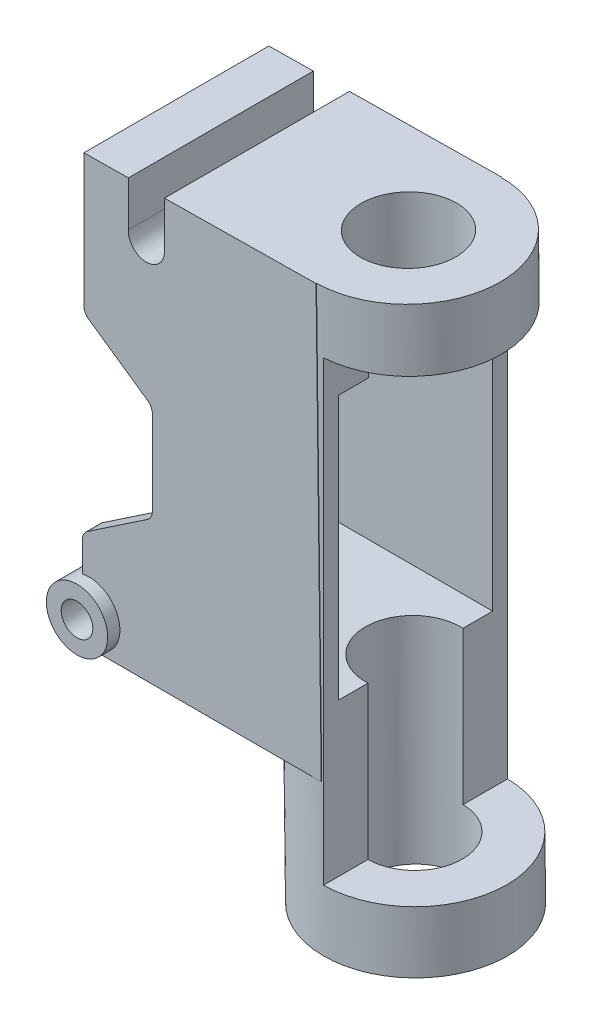
from build123d import *

# Parameters (mm, degrees)
BOSS_EXTRUDE1_DEPTH               = 60.325
BOSS_EXTRUDE2_START               = -64.325
SKETCH4_R                         = 10
BOSS_EXTRUDE2_DEPTH               = 68.325
SKETCH5_R                         = 5.159375
CUT_EXTRUDE1_DEPTH                = 69.325
SKETCH6_W                         = 75.649114878
SKETCH6_H                         = 60.325
BOSS_EXTRUDE3_DEPTH               = 1.8288
BOSS_EXTRUDE4_REACH               = 190.905
BOSS_EXTRUDE4_OFFSET_FROM_SURFACE = 49
SKETCH8_R                         = 30
SKETCH9_R                         = 15.5
CUT_EXTRUDE2_DEPTH                = 190.266787166
CUT_EXTRUDE3_DEPTH                = 49
SKETCH11_W                        = 50.325
SKETCH11_H                        = 86.143116626
CUT_EXTRUDE4_DEPTH                = 109.525496818
SKETCH15_R                        = 3.175
CUT_EXTRUDE5_DEPTH                = 190.266787166
FILLET1_R                         = 3.81


with BuildPart() as part:
    # Sketch2 → Boss-Extrude1 (new body)
    with BuildSketch(Plane.XY):
        with BuildLine():
            Line((12.765629792, 129.146573189), (-1.754589441, 128.968962917))
            Line((-1.754589441, 128.968962917), (-1.754589441, 83.82382539))
            Line((-1.754589441, 83.82382539), (20.592124083, 68.316599476))
            Line((20.592124083, 68.316599476), (20.592124083, 36.846052768))
            Line((20.592124083, 36.846052768), (-2.252403515, 21.475974179))
            Line((-2.252403515, 21.475974179), (-2.252403515, 12.414958495))
            Line((-2.252403515, 12.414958495), (-2.252403515, -8.161795964))
            Line((-2.252403515, -8.161795964), (75.649114878, -8.161795964))
            Line((75.649114878, -8.161795964), (73.96041286, 129.895103354))
            Line((73.96041286, 129.895103354), (24.530310461, 129.290477913))
            Line((24.530310461, 129.290477913), (24.530310461, 114.148644142))
            ThreePointArc((24.530310461, 114.148644142), (18.82597029, 108.263437866), (12.765629792, 113.781356201))
            ThreePointArc((12.765629792, 113.781356201), (12.754163231, 114.148644142), (12.765629792, 114.515932083))
            Line((12.765629792, 114.515932083), (12.765629792, 129.146573189))
        make_face()
    extrude(amount=BOSS_EXTRUDE1_DEPTH)

    # Sketch4 → Boss-Extrude2 (add)
    with BuildSketch(Plane.XY.offset(60.325).offset(BOSS_EXTRUDE2_START)):
        Circle(SKETCH4_R)
    extrude(amount=BOSS_EXTRUDE2_DEPTH)

    # Sketch5 → Cut-Extrude1 (cut, through all)
    with BuildSketch(Plane.XY.offset(64.325)):
        Circle(SKETCH5_R)
    extrude(amount=-CUT_EXTRUDE1_DEPTH, mode=Mode.SUBTRACT)

    # Sketch6 → Boss-Extrude3 (add)
    with BuildSketch(Plane.XZ.offset(8.161795964)):
        with Locations((37.824557439, 30.1625)):
            Rectangle(SKETCH6_W, SKETCH6_H)
    extrude(amount=BOSS_EXTRUDE3_DEPTH)

    # Boss-Extrude4: up to this face of the body (flat: up to its plane, moved by the offset)
    boss_extrude4_end = Plane(part.part.faces().sort_by_distance((38.041347827, -9.990595964, 30.1625))[0]).offset(BOSS_EXTRUDE4_OFFSET_FROM_SURFACE)
    # Sketch8 → Boss-Extrude4 (add, up to the picked face)
    with BuildSketch(Plane(origin=(-1.577565522, 128.97112826, 0), x_dir=(0.999925198, 0.012231013, 0), z_dir=(-0.012231013, 0.999925198, 0)), mode=Mode.PRIVATE) as boss_extrude4_sk1:
        with Locations((75.543629169, -30.1625)):
            Circle(SKETCH8_R)
    boss_extrude4_tool1 = split(extrude(boss_extrude4_sk1.sketch, amount=-BOSS_EXTRUDE4_REACH, mode=Mode.PRIVATE), bisect_by=boss_extrude4_end, keep=Keep.BOTH, mode=Mode.PRIVATE)
    add(boss_extrude4_tool1.solids().sort_by_distance((73.960413, 129.895103, 30.1625))[0])

    # Sketch9 → Cut-Extrude2 (cut, through all)
    with BuildSketch(Plane(origin=(-1.577565522, 128.97112826, 0), x_dir=(0.999925198, 0.012231013, 0), z_dir=(-0.012231013, 0.999925198, 0))):
        with Locations((75.543629169, -30.1625)):
            Circle(SKETCH9_R)
    extrude(amount=-CUT_EXTRUDE2_DEPTH, mode=Mode.SUBTRACT)

    # Sketch10 → Cut-Extrude3 (cut)
    with BuildSketch(Plane.ZY.offset(-125.245410559)):
        Polygon((60.325, 109.914722857), (60.1625, -38.990595964), (-4.123053696, -38.990595964), (-4.123053696, 109.914722857), align=None)
    extrude(amount=CUT_EXTRUDE3_DEPTH, mode=Mode.SUBTRACT)

    # Sketch11 → Cut-Extrude4 (cut, through all)
    with BuildSketch(Plane.ZY.offset(2.252403515)):
        with Locations((30.1625, 53.897404604)):
            Rectangle(SKETCH11_W, SKETCH11_H)
    extrude(amount=-CUT_EXTRUDE4_DEPTH, mode=Mode.SUBTRACT)

    # Sketch15 → Cut-Extrude5 (cut, through all)
    with BuildSketch(Plane(origin=(-1.577565522, 128.97112826, 0), x_dir=(0.999925198, 0.012231013, 0), z_dir=(-0.012231013, 0.999925198, 0))):
        with Locations((20.227048665, -30.1625)):
            Circle(SKETCH15_R)
    extrude(amount=-CUT_EXTRUDE5_DEPTH, mode=Mode.SUBTRACT)

    # Fillet1
    fillet1_edges = [part.edges().sort_by_distance(p)[0] for p in [
        (-2.252403515, 21.475974179, 2.5),
        (20.592124083, 36.846052768, 2.5),
        (20.592124083, 68.316599476, 2.5),
        (-1.754589441, 83.82382539, 2.5),
        (-2.252403515, 21.475974179, 57.825),
        (20.592124083, 36.846052768, 57.825),
        (20.592124083, 68.316599476, 57.825),
        (-1.754589441, 83.82382539, 57.825),
    ]]
    fillet(fillet1_edges, radius=FILLET1_R)


solid = part.part
